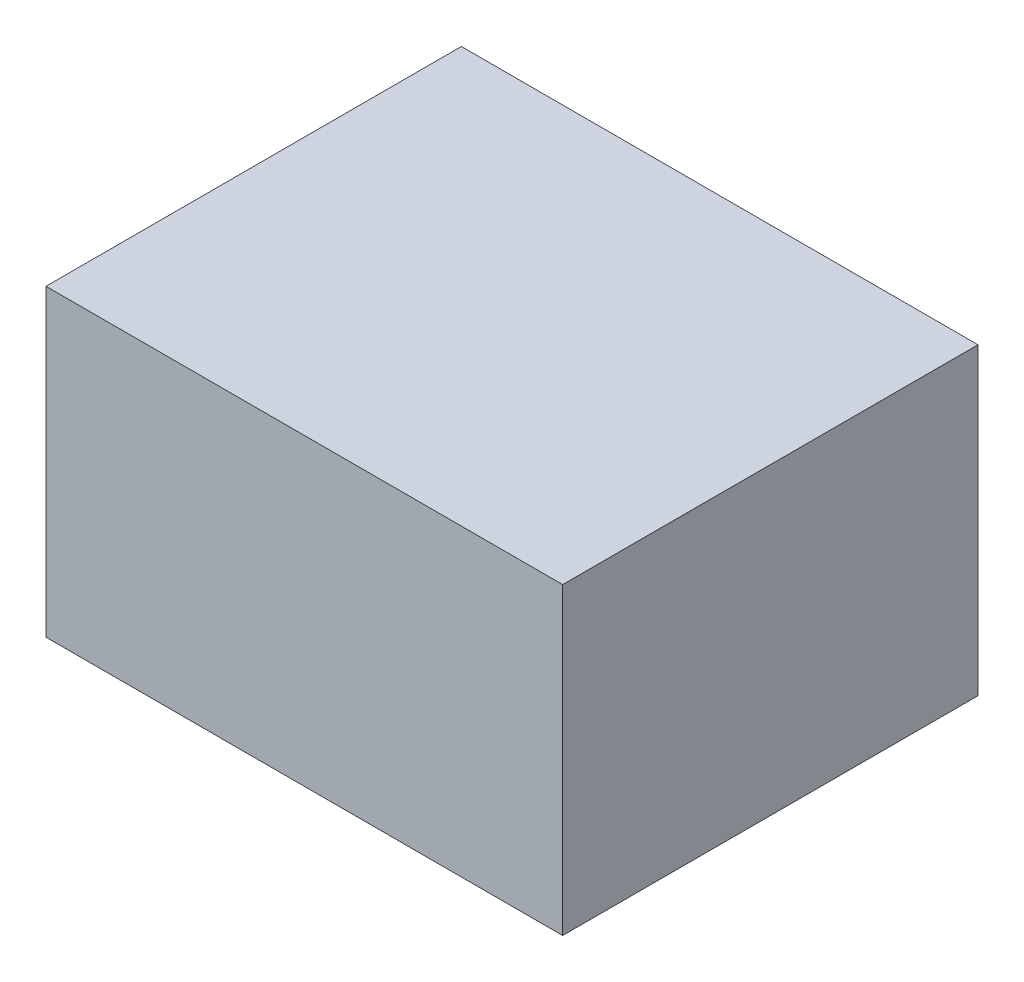
from build123d import *

# Parameters (mm, degrees)
SKETCH4_W           = 204
SKETCH4_H           = 164
BOSS_EXTRUDE3_DEPTH = 120
SKETCH5_W           = 200
SKETCH5_H           = 160
CUT_EXTRUDE2_DEPTH  = 116


with BuildPart() as part:
    # Sketch4 → Boss-Extrude3 (new body)
    with BuildSketch(Plane(origin=(0, 0, 0), x_dir=(1, 0, 0), z_dir=(0, 1, 0))):
        Rectangle(SKETCH4_W, SKETCH4_H)
    extrude(amount=BOSS_EXTRUDE3_DEPTH)

    # Sketch5 → Cut-Extrude2 (cut)
    with BuildSketch(Plane(origin=(0, 0, 0), x_dir=(1, 0, 0), z_dir=(0, 1, 0))):
        Rectangle(SKETCH5_W, SKETCH5_H)
    extrude(amount=CUT_EXTRUDE2_DEPTH, mode=Mode.SUBTRACT)


solid = part.part
